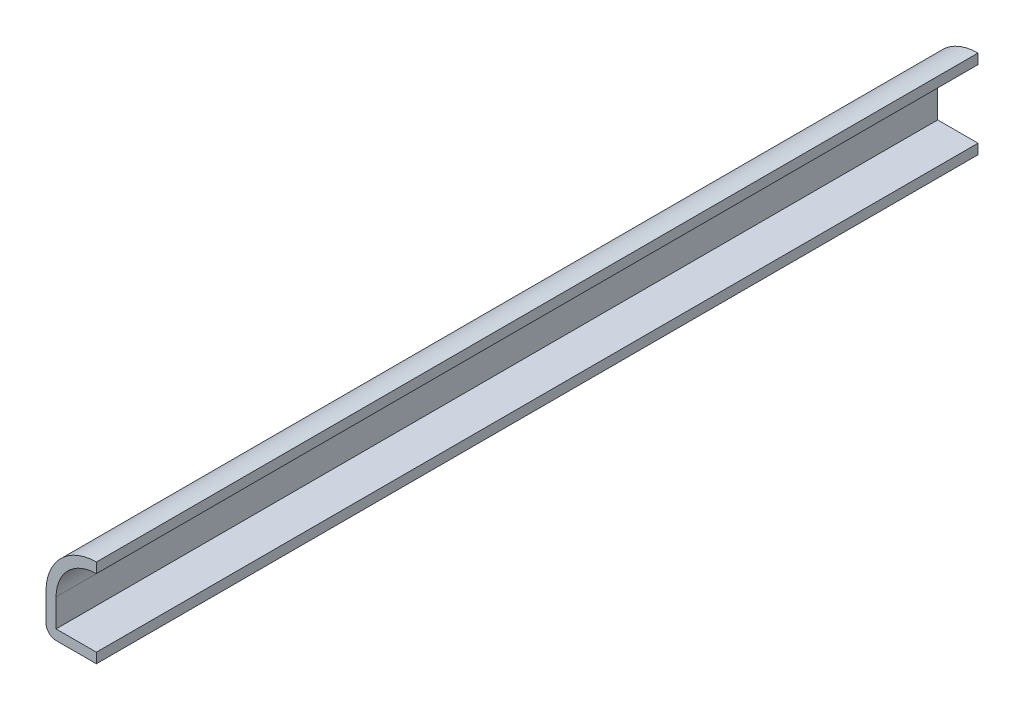
from build123d import *

# Parameters (mm, degrees)
EXTRUDE_THIN1_DEPTH = 111.125
FILLET1_R           = 1.27


with BuildPart() as part:
    # Sketch1 → Extrude-Thin1 (new body)
    with BuildSketch(Plane.XY):
        with BuildLine():
            Line((0, 0), (-6.35, 0))
            Line((-6.35, 0), (-6.35, 4.7625))
            ThreePointArc((-6.35, 4.7625), (-4.490128061, 9.252628061), (0, 11.1125))
            Line((0, 11.1125), (0, 9.8425))
            ThreePointArc((0, 9.8425), (-3.592102448, 8.354602448), (-5.08, 4.7625))
            Line((-5.08, 4.7625), (-5.08, 1.27))
            Line((-5.08, 1.27), (0, 1.27))
            Line((0, 1.27), (0, 0))
        make_face()
    extrude(amount=-EXTRUDE_THIN1_DEPTH)

    # Fillet1
    fillet1_edges = [part.edges().sort_by_distance(p)[0] for p in [
        (-6.35, 0, -55.5625),
    ]]
    fillet(fillet1_edges, radius=FILLET1_R)


solid = part.part
